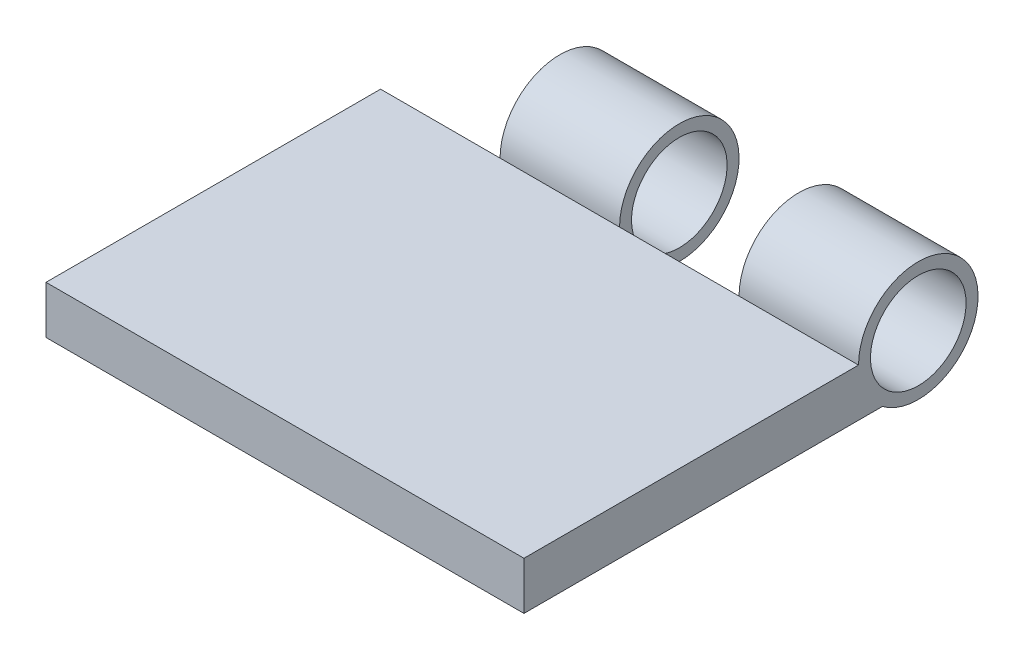
from build123d import *

# Parameters (mm, degrees)
SKETCH2_W           = 20
SKETCH2_H           = 14
BOSS_EXTRUDE2_DEPTH = 2
BOSS_EXTRUDE3_DEPTH = 5
SKETCH4_R           = 2
CUT_EXTRUDE1_DEPTH  = 21


with BuildPart() as part:
    # Sketch2 → Boss-Extrude2 (new body)
    with BuildSketch(Plane(origin=(0, 0, 0), x_dir=(1, 0, 0), z_dir=(0, 1, 0))):
        Rectangle(SKETCH2_W, SKETCH2_H)
    extrude(amount=BOSS_EXTRUDE2_DEPTH)

    # Sketch3 → Boss-Extrude3 (add)
    with BuildSketch(Plane(origin=(10, 0, 0), x_dir=(0, 0, -1), z_dir=(1, 0, 0))):
        with BuildLine():
            Line((12, 2), (7, 2))
            Line((7, 2), (7, 0))
            Line((7, 0), (8, 0))
            ThreePointArc((8, 0), (10.618033989, -0.236067977), (12, 2))
        make_face()
        with BuildLine():
            ThreePointArc((12, 2), (9.5, 4.5), (7, 2))
            Line((7, 2), (12, 2))
        make_face()
    boss_extrude3 = extrude(amount=-BOSS_EXTRUDE3_DEPTH)

    # Mirror1: Boss-Extrude3 across plane
    add(boss_extrude3.mirror(Plane.ZY.offset(-2.5)))

    # Sketch4 → Cut-Extrude1 (cut, through all)
    with BuildSketch(Plane(origin=(10, 0, 0), x_dir=(0, 0, -1), z_dir=(1, 0, 0))):
        with Locations((9.5, 2)):
            Circle(SKETCH4_R)
    extrude(amount=-CUT_EXTRUDE1_DEPTH, mode=Mode.SUBTRACT)


solid = part.part
